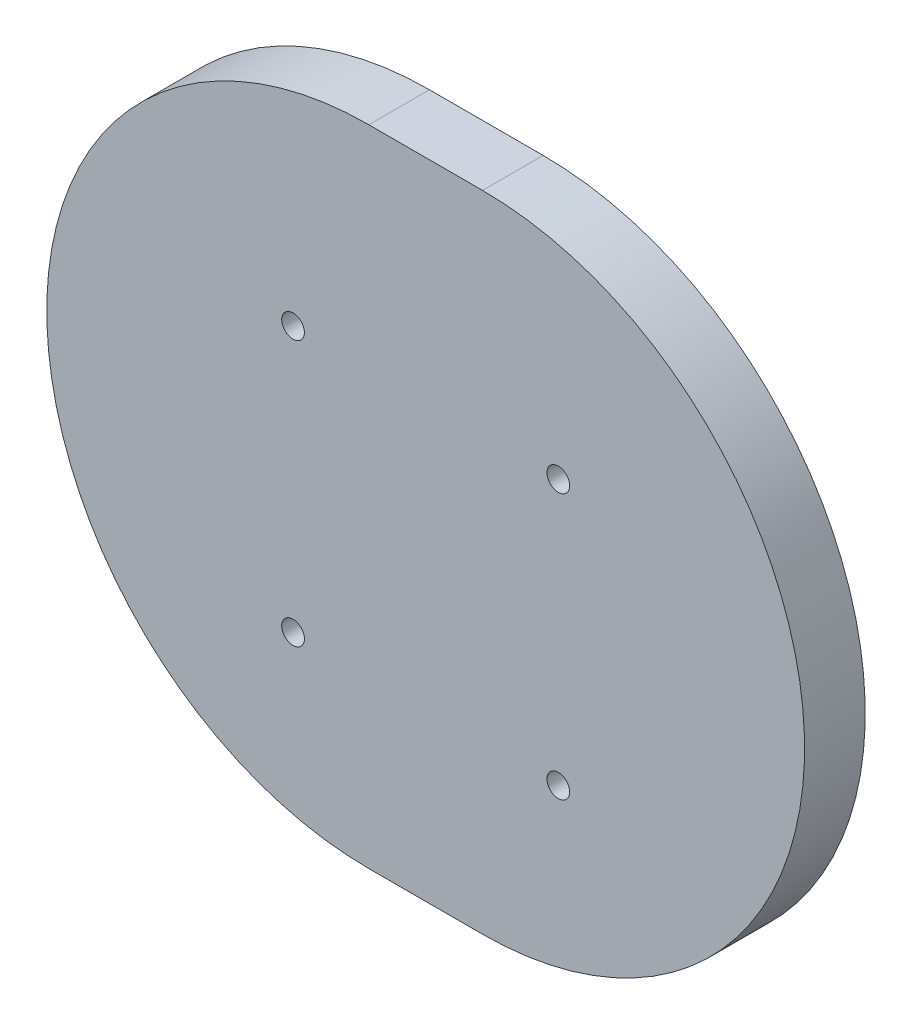
from build123d import *

# Parameters (mm, degrees)
SKETCH1_R           = 0.3
BOSS_EXTRUDE1_DEPTH = 1.6


with BuildPart() as part:
    # Sketch1 → Boss-Extrude1 (new body)
    with BuildSketch(Plane.XY):
        with BuildLine():
            Line((-1.5, 8.5), (1.5, 8.5))
            ThreePointArc((1.5, 8.5), (10, 0), (1.5, -8.5))
            Line((1.5, -8.5), (-1.5, -8.5))
            ThreePointArc((-1.5, -8.5), (-10, 0), (-1.5, 8.5))
        make_face()
        with Locations((3.5, 2.9)):
            Circle(SKETCH1_R, mode=Mode.SUBTRACT)
        with Locations((-3.5, 2.9)):
            Circle(SKETCH1_R, mode=Mode.SUBTRACT)
        with Locations((-3.5, -4.1)):
            Circle(SKETCH1_R, mode=Mode.SUBTRACT)
        with Locations((3.5, -4.1)):
            Circle(SKETCH1_R, mode=Mode.SUBTRACT)
    extrude(amount=BOSS_EXTRUDE1_DEPTH)


solid = part.part
